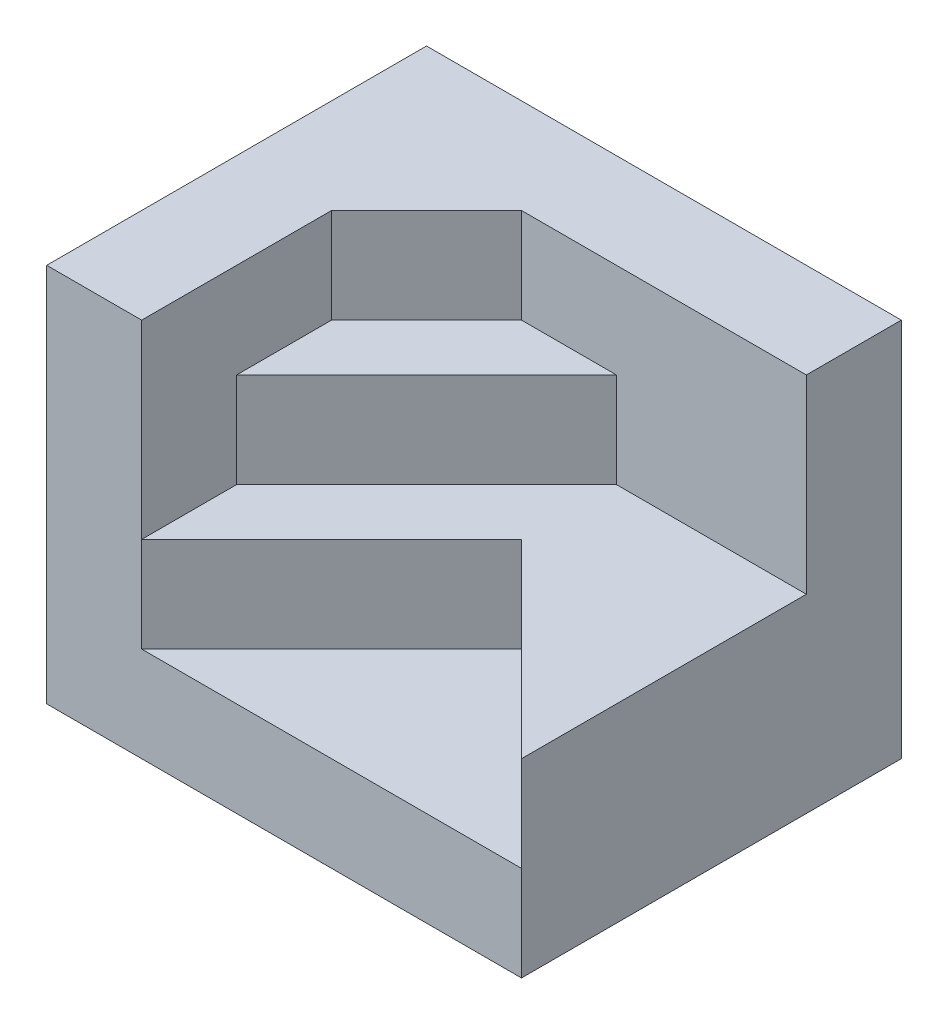
from build123d import *

# Parameters (mm, degrees)
EXTRUDE_2_DEPTH = 4
EXTRUDE_3_DEPTH = 3
EXTRUDE_4_DEPTH = 2
EXTRUDE_5_DEPTH = 1


with BuildPart() as part:
    # 草圖1 → 填料-伸長2 (new body)
    with BuildSketch(Plane(origin=(0, 0, 0), x_dir=(1, 0, 0), z_dir=(0, 1, 0))):
        Polygon((-2.5, -2), (-1.5, -2), (-1.5, 0), (-0.5, 1), (2.5, 1), (2.5, 2), (-2.5, 2), align=None)
    extrude(amount=EXTRUDE_2_DEPTH)

    # 草圖1<4> → 填料-伸長3 (add)
    with BuildSketch(Plane(origin=(0, 0, 0), x_dir=(1, 0, 0), z_dir=(0, 1, 0))):
        Polygon((-1.5, 0), (-1.5, -1), (0.5, 1), (-0.5, 1), align=None)
    extrude(amount=EXTRUDE_3_DEPTH)

    # 草圖1<5> → 填料-伸長4 (add)
    with BuildSketch(Plane(origin=(0, 0, 0), x_dir=(1, 0, 0), z_dir=(0, 1, 0))):
        Polygon((-1.5, -1), (-1.5, -2), (0.5, 0), (2.5, -2), (2.5, 1), (0.5, 1), align=None)
    extrude(amount=EXTRUDE_4_DEPTH)

    # 草圖1<6> → 填料-伸長5 (add)
    with BuildSketch(Plane(origin=(0, 0, 0), x_dir=(1, 0, 0), z_dir=(0, 1, 0))):
        Polygon((0.5, 0), (-1.5, -2), (2.5, -2), align=None)
    extrude(amount=EXTRUDE_5_DEPTH)


solid = part.part
